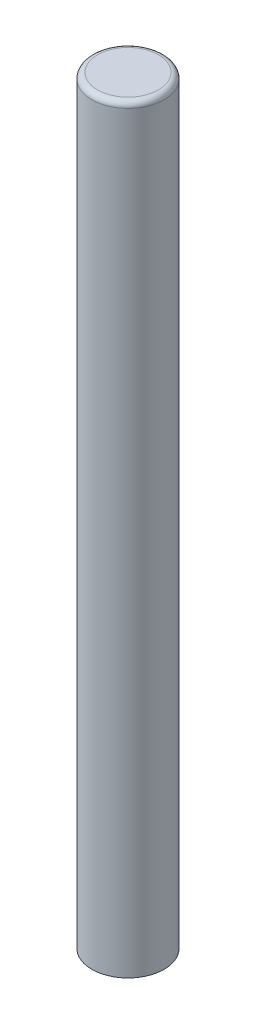
from build123d import *

# Parameters (mm, degrees)
SKETCH1_R           = 9.525
BOSS_EXTRUDE1_DEPTH = 200
FILLET1_R           = 1.5


with BuildPart() as part:
    # Sketch1 → Boss-Extrude1 (new body)
    with BuildSketch(Plane(origin=(0, 0, 0), x_dir=(1, 0, 0), z_dir=(0, 1, 0))):
        Circle(SKETCH1_R)
    extrude(amount=BOSS_EXTRUDE1_DEPTH)

    # Fillet1
    fillet1_edges = [part.edges().sort_by_distance(p)[0] for p in [
        (-9.525, 200, 0),
    ]]
    fillet(fillet1_edges, radius=FILLET1_R)


solid = part.part
